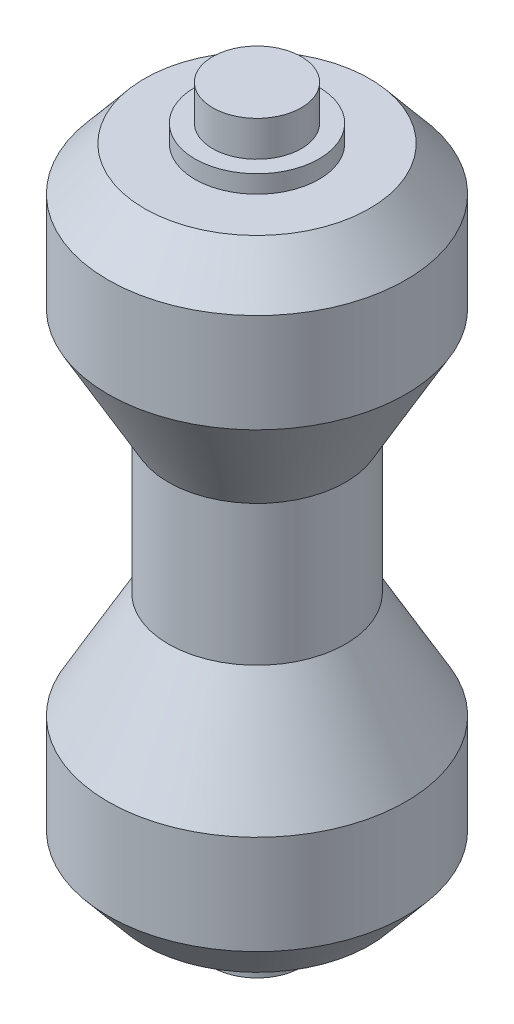
from build123d import *


with BuildPart() as part:
    # Sketch1 → Revolve1 (revolve)
    with BuildSketch(Plane.XY):
        Polygon((0, 34.572999671), (0, 13.572999671), (5, 13.572999671), (5, 17.52594584), (8.402394853, 23.52594584), (8.402394853, 29.111258282), (6.350943696, 31.572999671), (3.5, 31.572999671), (3.5, 32.572999671), (2.5, 32.572999671), (2.5, 34.572999671), align=None)
    revolve1 = revolve(axis=Axis((0, 34.572999671, 0), (0, -1, 0)))

    # Mirror1: Revolve1 across plane
    add(revolve1.mirror(Plane.ZX.offset(13.572999671)))


solid = part.part
